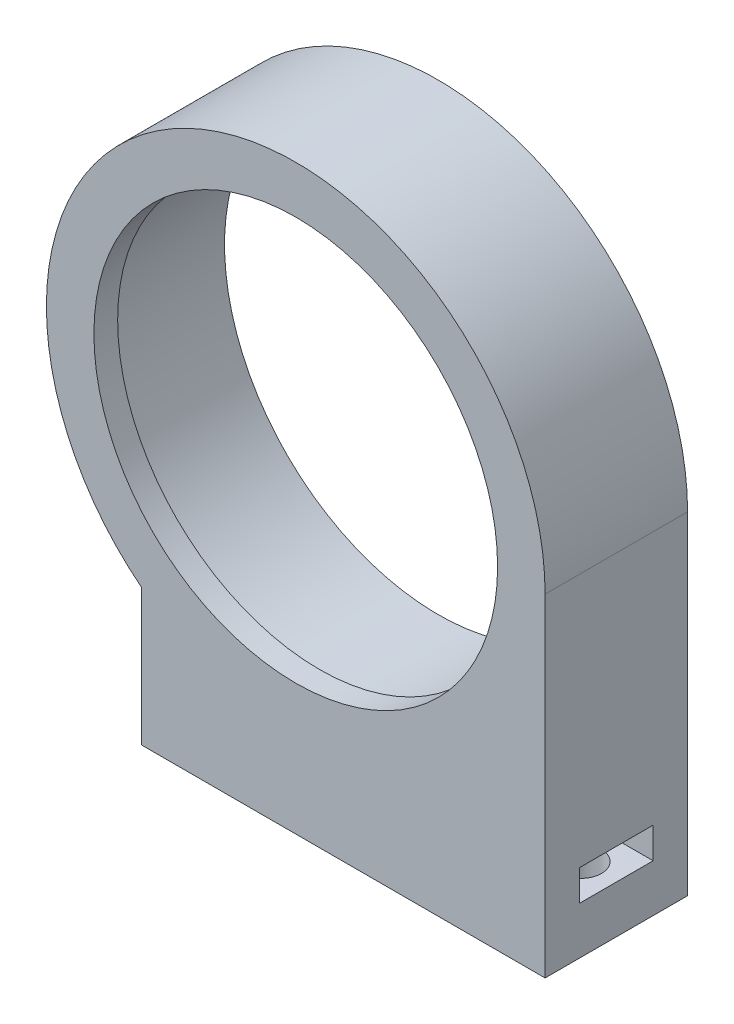
from build123d import *
from build123d.topology import SkipClean

# Parameters (mm, degrees)
CROQUIS1_R              = 18
SALIENTE_EXTRUIR1_DEPTH = 10
CROQUIS2_R              = 17
SALIENTE_EXTRUIR2_DEPTH = 2
CROQUIS7_R              = 1.75
CORTAR_EXTRUIR3_DEPTH   = 8
CORTAR_EXTRUIR4_DEPTH   = 2.6


with BuildPart() as part:
    # Croquis1 → Saliente-Extruir1 (new body)
    with BuildSketch(Plane.XY):
        with BuildLine():
            Line((-13, -28), (21, -28))
            Line((21, -28), (21, 0))
            ThreePointArc((21, 0), (-9.16515139, 18.894443628), (-13, -16.492422502))
            Line((-13, -16.492422502), (-13, -28))
        make_face()
        Circle(CROQUIS1_R, mode=Mode.SUBTRACT)
    extrude(amount=SALIENTE_EXTRUIR1_DEPTH)

    # Croquis2 → Saliente-Extruir2 (add)
    with SkipClean():  # the faces are left unmerged after this step: merging them gives an invalid solid
        with BuildSketch(Plane.XY.offset(10)):
            with BuildLine():
                Line((21, 0), (21, -28))
                Line((21, -28), (-13, -28))
                Line((-13, -28), (-13, -16.492422502))
                ThreePointArc((-13, -16.492422502), (-9.16515139, 18.894443628), (21, 0))
            make_face()
            Circle(CROQUIS2_R, mode=Mode.SUBTRACT)
        extrude(amount=SALIENTE_EXTRUIR2_DEPTH)

    # Croquis7 → Cortar-Extruir3 (cut)
    with SkipClean():  # the faces are left unmerged after this step: merging them gives an invalid solid
        with BuildSketch(Plane.XZ.offset(28)):
            with Locations((-10, 6)):
                Circle(CROQUIS7_R)
            with Locations((18, 6)):
                Circle(CROQUIS7_R)
        extrude(amount=-CORTAR_EXTRUIR3_DEPTH, mode=Mode.SUBTRACT)

    # Croquis8 → Cortar-Extruir4 (cut)
    with SkipClean():  # the faces are left unmerged after this step: merging them gives an invalid solid
        with BuildSketch(Plane(origin=(0, -24, 0), x_dir=(-1, 0, 0), z_dir=(0, -1, 0))):
            with BuildLine():
                Line((-18, -2.9), (-21, -2.9))
                Line((-21, -2.9), (-21, -9.1))
                Line((-21, -9.1), (-18, -9.1))
                ThreePointArc((-18, -9.1), (-14.9, -6), (-18, -2.9))
            make_face()
            with BuildLine():
                Line((10, -2.9), (13, -2.9))
                Line((13, -2.9), (13, -9.1))
                Line((13, -9.1), (10, -9.1))
                ThreePointArc((10, -9.1), (6.9, -6), (10, -2.9))
            make_face()
        extrude(amount=-CORTAR_EXTRUIR4_DEPTH, mode=Mode.SUBTRACT)


solid = part.part
